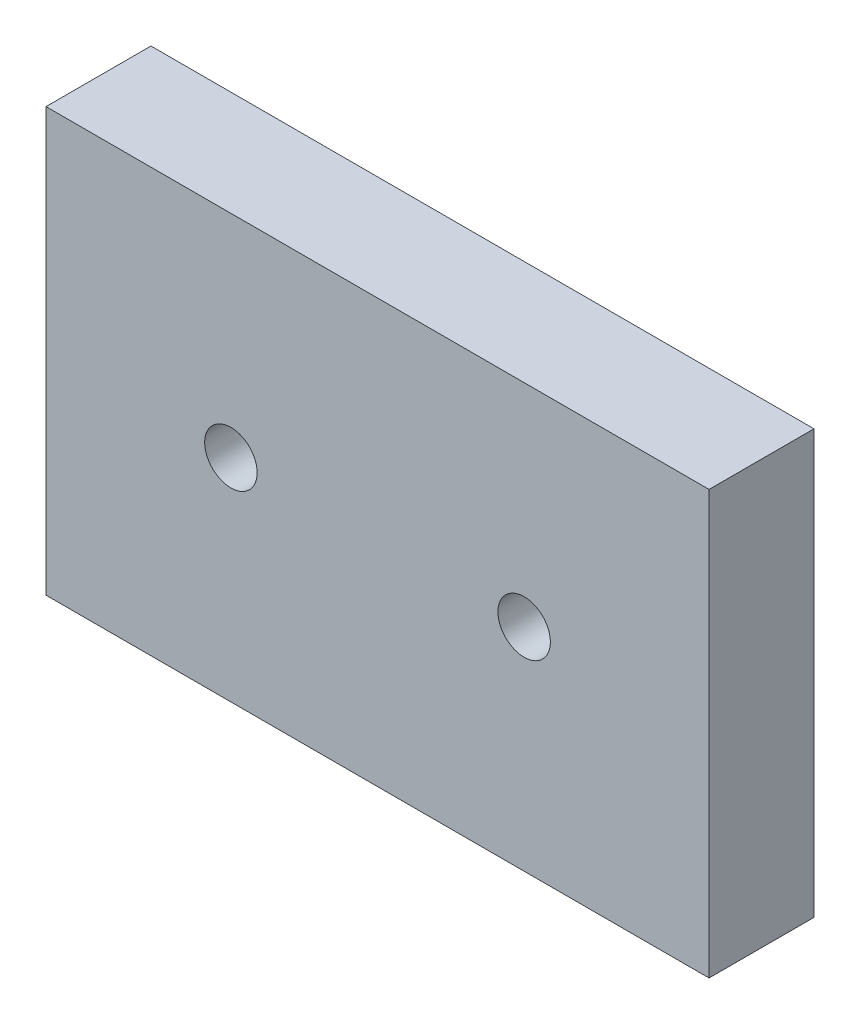
from build123d import *

# Parameters (mm, degrees)
SKETCH1_W           = 63.18
SKETCH1_H           = 40.32
SKETCH1_R           = 2.5
BOSS_EXTRUDE1_DEPTH = 10


with BuildPart() as part:
    # Sketch1 → Boss-Extrude1 (new body)
    with BuildSketch(Plane.XY):
        with Locations((21.59, 10.16)):
            Rectangle(SKETCH1_W, SKETCH1_H)
        with Locations((35.56, 10.16)):
            Circle(SKETCH1_R, mode=Mode.SUBTRACT)
        with Locations((7.62, 10.16)):
            Circle(SKETCH1_R, mode=Mode.SUBTRACT)
    extrude(amount=BOSS_EXTRUDE1_DEPTH)


solid = part.part
